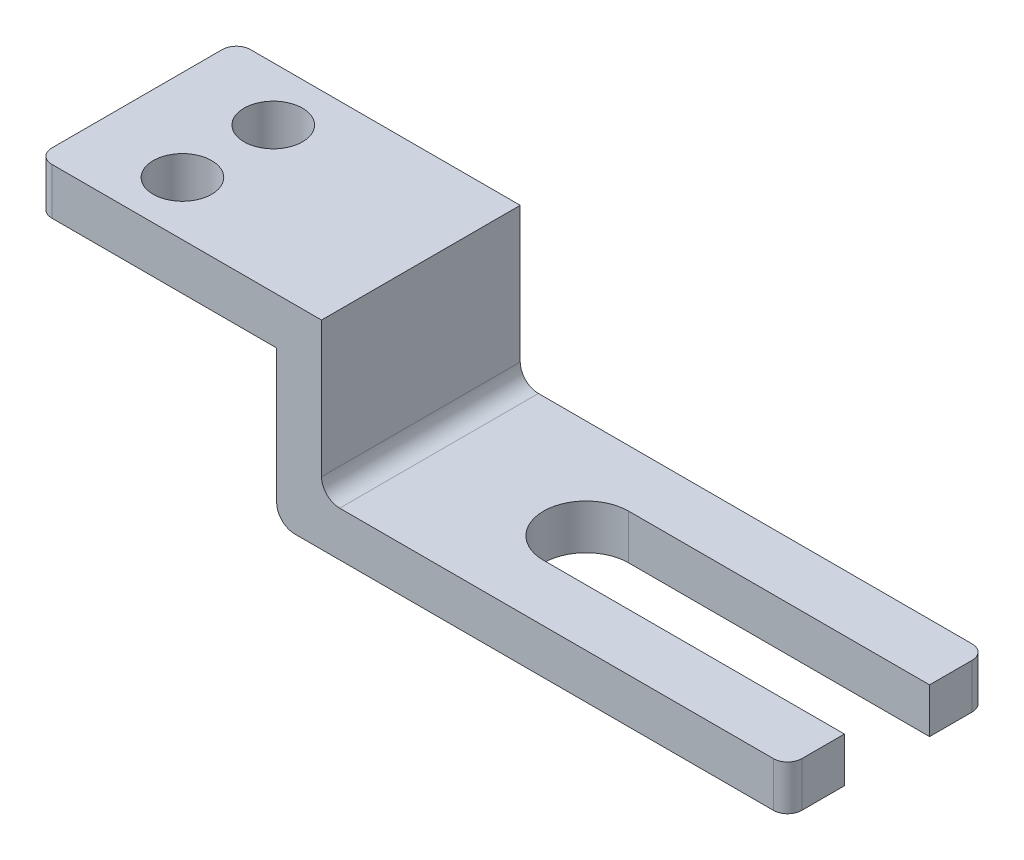
from build123d import *

# Parameters (mm, degrees)
SKETCH1_W               = 6710.68
SKETCH1_H               = 1778
EXTRUDE1_DEPTH          = 1778
CUT_EXTRUDE3_DEPTH      = 1
CUT_EXTRUDE3_DEPTH_BACK = 1779
CUT_EXTRUDE4_DEPTH      = 1
CUT_EXTRUDE4_DEPTH_BACK = 1779
CUT_EXTRUDE5_DEPTH      = 1377.68
CUT_EXTRUDE5_DEPTH_BACK = 402.32
SKETCH9_R               = 261.62
CUT_EXTRUDE6_DEPTH      = 1779
FILLET2_R               = 162.56
FILLET3_R               = 162.56
FILLET4_R               = 127


with BuildPart() as part:
    # Sketch1 → Extrude1 (new body)
    with BuildSketch(Plane.XY):
        with Locations((3294.345792298, -853.619018308)):
            Rectangle(SKETCH1_W, SKETCH1_H)
    extrude(amount=-EXTRUDE1_DEPTH)

    # Sketch2 → Cut-Extrude3 (cut, two sides)
    with BuildSketch(Plane.XY) as cut_extrude3_sk:
        Polygon((-13765.426569294, -382.051723335), (-60.994207702, -382.051723335), (2077.685792298, -382.051723335), (2077.685792298, -1758.731723335), (2077.685792298, -15463.164084926), (-16820.007425204, -35315.696831932), (-32663.119786796, -20234.58447034), align=None)
    extrude(amount=CUT_EXTRUDE3_DEPTH, mode=Mode.SUBTRACT)
    extrude(cut_extrude3_sk.sketch, amount=-CUT_EXTRUDE3_DEPTH_BACK, mode=Mode.SUBTRACT)

    # Sketch6 → Cut-Extrude4 (cut, two sides)
    with BuildSketch(Plane.XY) as cut_extrude4_sk:
        Polygon((2479.005792298, 13746.253053907), (2479.005792298, 35.380981692), (2479.005792298, -1341.299018308), (6649.685792298, -1341.299018308), (20360.557864513, -1341.299018308), (38044.03863857, 19616.910820228), (20162.486566356, 34704.462892443), align=None)
    extrude(amount=CUT_EXTRUDE4_DEPTH, mode=Mode.SUBTRACT)
    extrude(cut_extrude4_sk.sketch, amount=-CUT_EXTRUDE4_DEPTH_BACK, mode=Mode.SUBTRACT)

    # Sketch8 → Cut-Extrude5 (cut, two sides)
    with BuildSketch(Plane(origin=(0, -1341.299018308, 0), x_dir=(-1, 0, 0), z_dir=(0, 1, 0))) as cut_extrude5_sk:
        with BuildLine():
            Line((-20319.279646055, -508), (-6649.685792298, -508))
            Line((-6649.685792298, -508), (-3957.285792298, -508))
            ThreePointArc((-3957.285792298, -508), (-3576.285792298, -889), (-3957.285792298, -1270))
            Line((-3957.285792298, -1270), (-6649.685792298, -1270))
            Line((-6649.685792298, -1270), (-20319.279646055, -1270))
            Line((-20319.279646055, -1270), (-47658.467353569, -1270))
            Line((-47658.467353569, -1270), (-47658.467353569, -508))
            Line((-47658.467353569, -508), (-20319.279646055, -508))
        make_face()
    extrude(amount=CUT_EXTRUDE5_DEPTH, mode=Mode.SUBTRACT)
    extrude(cut_extrude5_sk.sketch, amount=-CUT_EXTRUDE5_DEPTH_BACK, mode=Mode.SUBTRACT)

    # Sketch9 → Cut-Extrude6 (cut, through all)
    with BuildSketch(Plane(origin=(0, 35.380981692, 0), x_dir=(-1, 0, 0), z_dir=(0, 1, 0))):
        with Locations((-751.805792298, -1295.4)):
            Circle(SKETCH9_R)
        with Locations((-751.805792298, -482.6)):
            Circle(SKETCH9_R)
    extrude(amount=-CUT_EXTRUDE6_DEPTH, mode=Mode.SUBTRACT)

    # Fillet2
    fillet2_edges = [part.edges().sort_by_distance(p)[0] for p in [
        (2479.005792298, -1341.299018308, -889),
    ]]
    fillet(fillet2_edges, radius=FILLET2_R)

    # Fillet3
    fillet3_edges = [part.edges().sort_by_distance(p)[0] for p in [
        (2077.685792298, -1742.619018308, -889),
    ]]
    fillet(fillet3_edges, radius=FILLET3_R)

    # Fillet4
    fillet4_edges = [part.edges().sort_by_distance(p)[0] for p in [
        (6649.685792298, -1541.959018308, -1778),
        (-60.994207702, -173.335370821, -1778),
        (6649.685792298, -1541.959018308, 0),
        (-60.994207702, -173.335370821, 0),
    ]]
    fillet(fillet4_edges, radius=FILLET4_R)


solid = part.part
